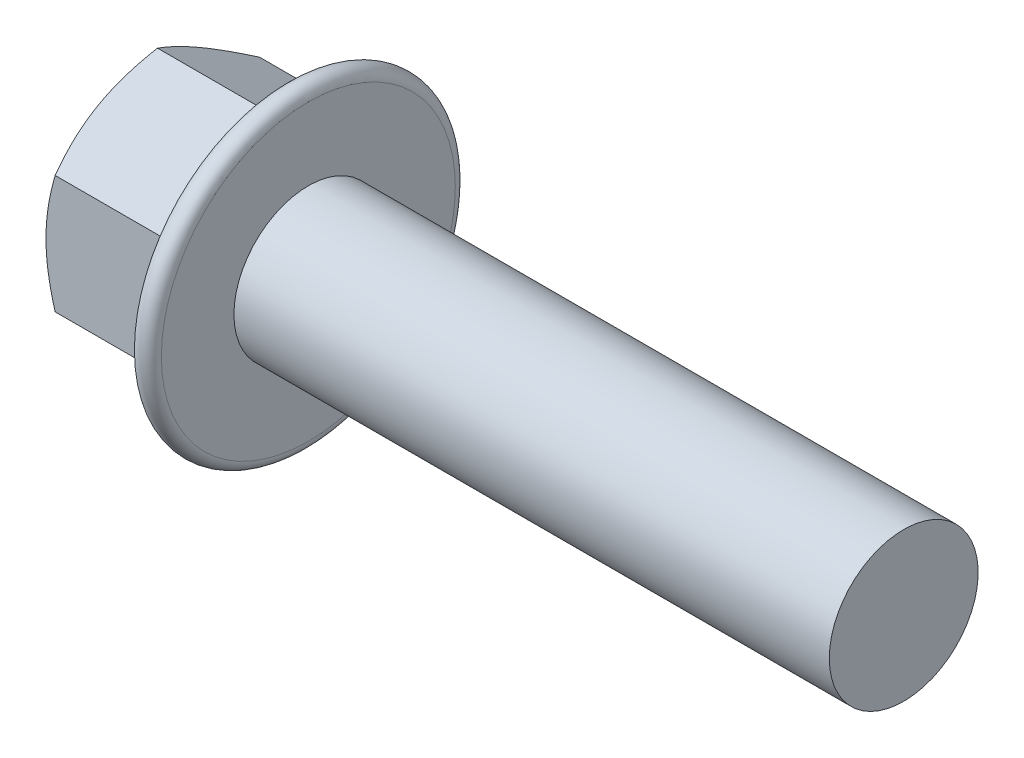
from build123d import *

# Parameters (mm, degrees)
SKETCH2_R         = 3.207274827
HEX_DIE_DEPTH     = 4.3
FLANGEHEXFILLET_R = 0.2
SKETCH4_R         = 2.40625
INDENT_DEPTH      = 0.358333333


with BuildPart() as part:
    # BodySke → Base-Revolve (revolve)
    with BuildSketch(Plane.XY, mode=Mode.PRIVATE) as base_revolve_sk:
        Polygon((4.3, 2), (4.3, 3.17551963), (0.245673873, 3.17551963), (0, 2.75), (0, 0), (20.3, 0), (20.3, 2), align=None)
    revolve(base_revolve_sk.sketch.rotate(Axis((-25.4, 0, 0), (1, 0, 0)), 90), axis=Axis((-25.4, 0, 0), (1, 0, 0)))

    # Sketch2 → Hex-Die (cut)
    with BuildSketch(Plane(origin=(0, 0, 0), x_dir=(0, 0, -1), z_dir=(1, 0, 0))):
        Circle(SKETCH2_R)
        Polygon((-2.75, 1.587713247), (0, 3.175426494), (2.75, 1.587713247), (2.75, -1.587713247), (0, -3.175426494), (-2.75, -1.587713247), align=None, mode=Mode.SUBTRACT)
    extrude(amount=HEX_DIE_DEPTH, mode=Mode.SUBTRACT)

    # Sketch5 → Flange (revolve)
    with BuildSketch(Plane.XY, mode=Mode.PRIVATE) as flange_sk:
        with BuildLine():
            Line((2.243064243, 0), (3.718092214, 4.052606043))
            ThreePointArc((3.718092214, 4.052606043), (4.052094453, 4.245442326), (4.3, 3.95))
            Line((4.3, 3.95), (4.3, 0))
            Line((4.3, 0), (2.243064243, 0))
        make_face()
    revolve(flange_sk.sketch.rotate(Axis((0, 0, 0), (1, 0, 0)), 90), axis=Axis((0, 0, 0), (1, 0, 0)))

    # FlangeHexFillet
    flangehexfillet_edges = [part.edges().sort_by_distance(p)[0] for p in [
        (3.285203168, 0.797319684, 2.75),
        (3.24398239, 2.381569871, 1.375),
        (3.24398239, 2.381569871, -1.375),
        (3.243982387, 0, -2.75),
        (3.24398239, -2.381569871, -1.375),
        (3.24398239, -2.381569871, 1.375),
        (3.285203168, -0.797319684, 2.75),
    ]]
    fillet(flangehexfillet_edges, radius=FLANGEHEXFILLET_R)

    # Sketch4 → Indent (cut)
    with BuildSketch(Plane(origin=(0, 0, 0), x_dir=(0, 0, -1), z_dir=(1, 0, 0))):
        with Locations(Location((0, 0, 0), (0, 0, 180))):
            Circle(SKETCH4_R)
    extrude(amount=INDENT_DEPTH, mode=Mode.SUBTRACT)


solid = part.part
